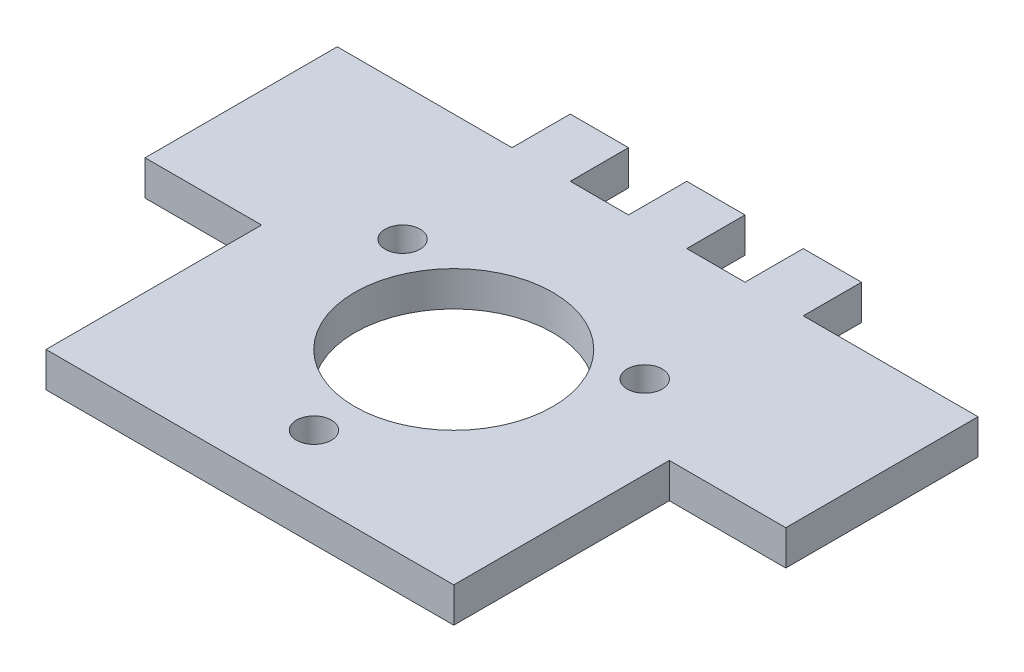
from build123d import *

# Parameters (mm, degrees)
ESQUISSE1_W                = 35
ESQUISSE1_H                = 35
BOSS_EXTRU_1_DEPTH         = 3
ESQUISSE2_W                = 5
ESQUISSE2_H                = 5
BOSS_EXTRU_2_DEPTH         = 3
R_P_TITION_LIN_AIRE1_COUNT = 3
R_P_TITION_LIN_AIRE1_PITCH = 10
ESQUISSE3_R                = 8.5
ESQUISSE3_R_2              = 1.5
ENL_V_MAT_EXTRU_1_DEPTH    = 5
ESQUISSE4_W                = 10
ESQUISSE4_H                = 16.5
BOSS_EXTRU_3_DEPTH         = 3


with BuildPart() as part:
    # Esquisse1 → Boss.-Extru.1 (new body)
    with BuildSketch(Plane(origin=(0, 0, 0), x_dir=(1, 0, 0), z_dir=(0, 1, 0))):
        Rectangle(ESQUISSE1_W, ESQUISSE1_H)
    extrude(amount=BOSS_EXTRU_1_DEPTH)

    # Esquisse2 → Boss.-Extru.2 (add)
    with BuildSketch(Plane(origin=(0, 3, 0), x_dir=(1, 0, 0), z_dir=(0, 1, 0))):
        with Locations((-10, 20)):
            Rectangle(ESQUISSE2_W, ESQUISSE2_H)
    boss_extru_2 = extrude(amount=-BOSS_EXTRU_2_DEPTH)

    # Répétition linéaire1: Boss.-Extru.2 ×3
    with Locations(*[(i * R_P_TITION_LIN_AIRE1_PITCH, 0, 0) for i in range(1, R_P_TITION_LIN_AIRE1_COUNT)]):
        add(boss_extru_2)

    # Esquisse3 → Enlèv. mat.-Extru.1 (cut)
    with BuildSketch(Plane(origin=(0, 3, 0), x_dir=(1, 0, 0), z_dir=(0, 1, 0))):
        Circle(ESQUISSE3_R)
        with Locations((0, -12)):
            Circle(ESQUISSE3_R_2)
        with Locations((-10.392304845, 6)):
            Circle(ESQUISSE3_R_2)
        with Locations((10.392304845, 6)):
            Circle(ESQUISSE3_R_2)
    extrude(amount=-ENL_V_MAT_EXTRU_1_DEPTH, mode=Mode.SUBTRACT)

    # Esquisse4 → Boss.-Extru.3 (add)
    with BuildSketch(Plane(origin=(0, 3, 0), x_dir=(1, 0, 0), z_dir=(0, 1, 0))):
        with Locations((-22.5, 9.25)):
            Rectangle(ESQUISSE4_W, ESQUISSE4_H)
    boss_extru_3 = extrude(amount=-BOSS_EXTRU_3_DEPTH)

    # Symétrie1: Boss.-Extru.3 across plane
    add(boss_extru_3.mirror(Plane(origin=(0, 0, 0), x_dir=(0, 0, 1), z_dir=(1, 0, 0))))


solid = part.part
